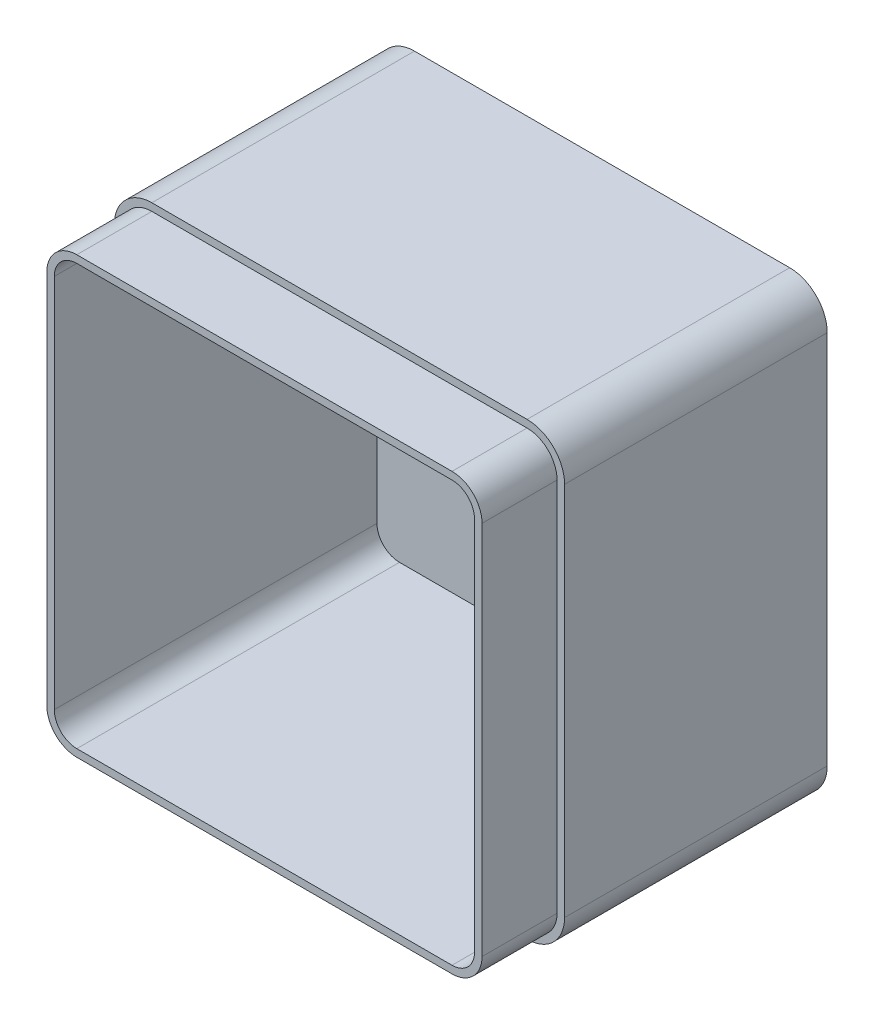
from build123d import *

# Parameters (mm, degrees)
SKETCH2_W           = 120
SKETCH2_H           = 120
BOSS_EXTRUDE1_DEPTH = 90
FILLET1_R           = 10
SHELL1_T            = -4
CUT_EXTRUDE7_DEPTH  = 20


with BuildPart() as part:
    # Sketch2 → Boss-Extrude1 (new body)
    with BuildSketch(Plane.XY):
        with Locations((60, 60)):
            Rectangle(SKETCH2_W, SKETCH2_H)
    extrude(amount=BOSS_EXTRUDE1_DEPTH)

    # Fillet1
    fillet1_edges = [part.edges().sort_by_distance(p)[0] for p in [
        (0, 120, 45),
        (120, 120, 45),
        (120, 0, 45),
        (0, 0, 45),
    ]]
    fillet(fillet1_edges, radius=FILLET1_R)

    # Shell1
    shell1_openings = [part.faces().sort_by_distance(p)[0] for p in [
        (60, 60, 90),
    ]]
    offset(amount=SHELL1_T, openings=shell1_openings, kind=Kind.INTERSECTION)

    # Sketch10 → Cut-Extrude7 (cut)
    with BuildSketch(Plane.XY.offset(90)):
        with BuildLine():
            Line((0, 110), (0, 10))
            ThreePointArc((0, 10), (2.928932188, 2.928932188), (10, 0))
            Line((10, 0), (110, 0))
            ThreePointArc((110, 0), (117.071067812, 2.928932188), (120, 10))
            Line((120, 10), (120, 110))
            ThreePointArc((120, 110), (117.071067812, 117.071067812), (110, 120))
            Line((110, 120), (10, 120))
            ThreePointArc((10, 120), (2.928932188, 117.071067812), (0, 110))
        make_face()
        with BuildLine():
            Line((2, 110), (2, 10))
            ThreePointArc((2, 10), (4.343145751, 4.343145751), (10, 2))
            Line((10, 2), (110, 2))
            ThreePointArc((110, 2), (115.656854249, 4.343145751), (118, 10))
            Line((118, 10), (118, 110))
            ThreePointArc((118, 110), (115.656854249, 115.656854249), (110, 118))
            Line((110, 118), (10, 118))
            ThreePointArc((10, 118), (4.343145751, 115.656854249), (2, 110))
        make_face(mode=Mode.SUBTRACT)
    extrude(amount=-CUT_EXTRUDE7_DEPTH, mode=Mode.SUBTRACT)


solid = part.part
